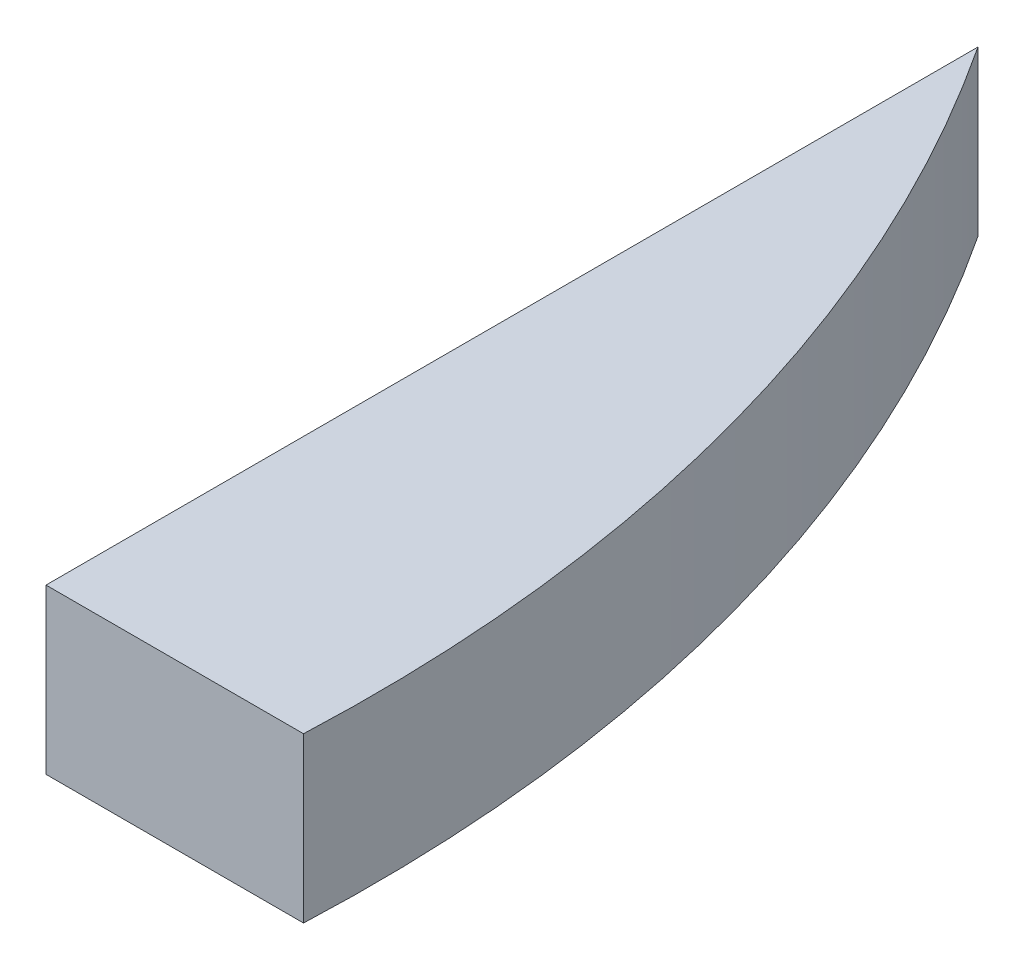
from build123d import *

# Parameters (mm, degrees)
BOSS_EXTRUDE1_DEPTH = 25.8


with BuildPart() as part:
    # Sketch1 → Boss-Extrude1 (new body)
    with BuildSketch(Plane.XZ.offset(25.8)):
        with BuildLine():
            Line((0, -142.57), (0, -146.669654615))
            ThreePointArc((0, -146.669654615), (20.636657337, -108.356820058), (34.24187868, -67.021086485))
            ThreePointArc((34.24187868, -67.021086485), (39.673003905, -33.725193348), (40.524446622, 0))
            Line((40.524446622, 0), (0, 0))
            Line((0, 0), (0, -142.57))
        make_face()
    extrude(amount=-BOSS_EXTRUDE1_DEPTH)


solid = part.part
